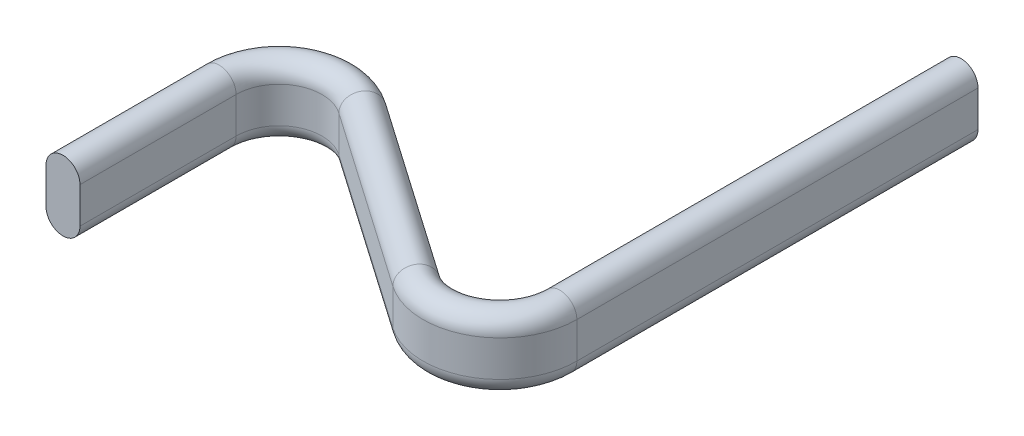
from build123d import *


with BuildPart() as part:
    # Sweep1: sweep along a path in Sketch2
    with BuildLine(Plane(origin=(0, 0, 0), x_dir=(1, 0, 0), z_dir=(0, 1, 0))) as sweep1_path:
        Line((0, 0), (0, 15.631722518))
        ThreePointArc((0, 15.631722518), (3.220069275, 20.948863212), (9.423995054, 20.55881678))
        Line((9.423995054, 20.55881678), (27.143102002, 8.245243845))
        ThreePointArc((27.143102002, 8.245243845), (33.347027781, 7.855197413), (36.567097056, 13.172338107))
        Line((36.567097056, 13.172338107), (36.567097056, 53.328590127))
    # Sketch1 → Sweep1 (sweep)
    with BuildSketch(Plane.XY):
        with BuildLine():
            Line((-1.7, -1.8), (-1.7, 1.8))
            ThreePointArc((-1.7, 1.8), (0, 3.5), (1.7, 1.8))
            Line((1.7, 1.8), (1.7, -1.8))
            ThreePointArc((1.7, -1.8), (0, -3.5), (-1.7, -1.8))
        make_face()
    sweep(path=sweep1_path.line)


solid = part.part
